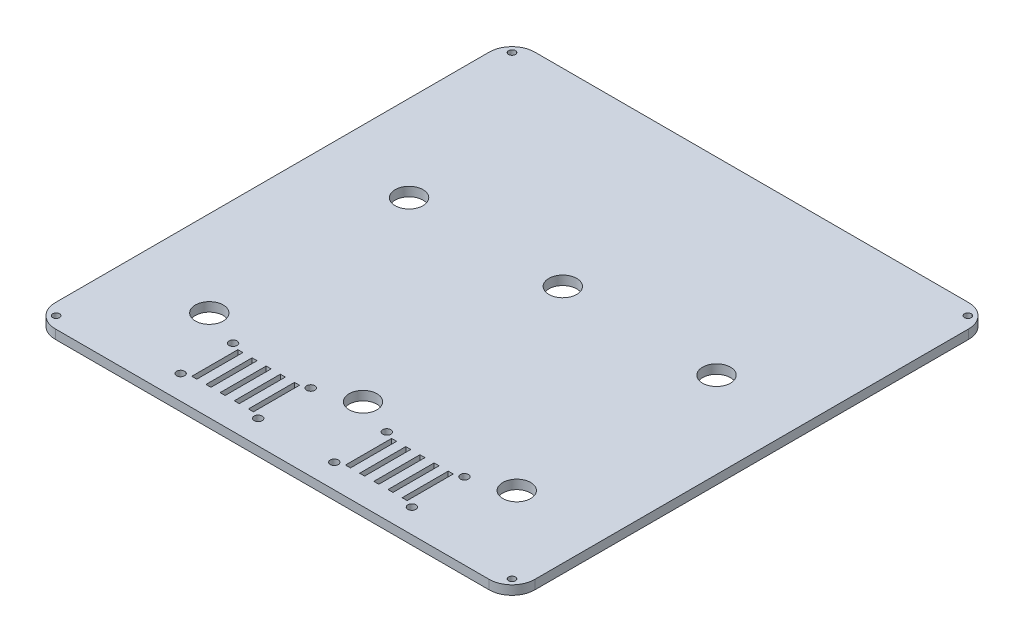
from build123d import *

# Parameters (mm, degrees)
SKETCH1_W         = 210
SKETCH1_H         = 210
SKETCH1_R         = 1.5
SKETCH1_R_2       = 6.1
SKETCH1_R_3       = 1.765
SKETCH1_W_2       = 2.2
SKETCH1_H_2       = 20.2
MAINEXTRUDE_DEPTH = 4
ROUNDEDCORNERS_R  = 10


with BuildPart() as part:
    # Sketch1 → MainExtrude (new body)
    with BuildSketch(Plane(origin=(0, 0, 0), x_dir=(1, 0, 0), z_dir=(0, 1, 0))):
        Rectangle(SKETCH1_W, SKETCH1_H)
        with Locations((-99.833273811, 99.833273811)):
            Circle(SKETCH1_R, mode=Mode.SUBTRACT)
        with Locations((-99.833273811, -99.833273811)):
            Circle(SKETCH1_R, mode=Mode.SUBTRACT)
        with Locations((99.833273811, -99.833273811)):
            Circle(SKETCH1_R, mode=Mode.SUBTRACT)
        with Locations((99.833273811, 99.833273811)):
            Circle(SKETCH1_R, mode=Mode.SUBTRACT)
        with Locations((67.333333333, -65.25)):
            Circle(SKETCH1_R_2, mode=Mode.SUBTRACT)
        with Locations((0, -65.25)):
            Circle(SKETCH1_R_2, mode=Mode.SUBTRACT)
        with Locations((-67.333333333, -65.25)):
            Circle(SKETCH1_R_2, mode=Mode.SUBTRACT)
        with Locations((-67.333333333, 22.25)):
            Circle(SKETCH1_R_2, mode=Mode.SUBTRACT)
        with Locations((0, 22.25)):
            Circle(SKETCH1_R_2, mode=Mode.SUBTRACT)
        with Locations((67.333333333, 22.25)):
            Circle(SKETCH1_R_2, mode=Mode.SUBTRACT)
        with Locations((-50.666666667, -71.5)):
            Circle(SKETCH1_R_3, mode=Mode.SUBTRACT)
        with Locations((-50.666666667, -94.5)):
            Circle(SKETCH1_R_3, mode=Mode.SUBTRACT)
        with Locations((-16.666666667, -94.5)):
            Circle(SKETCH1_R_3, mode=Mode.SUBTRACT)
        with Locations((-16.666666667, -71.5)):
            Circle(SKETCH1_R_3, mode=Mode.SUBTRACT)
        with Locations((16.666666667, -71.5)):
            Circle(SKETCH1_R_3, mode=Mode.SUBTRACT)
        with Locations((16.666666667, -94.5)):
            Circle(SKETCH1_R_3, mode=Mode.SUBTRACT)
        with Locations((50.666666667, -94.5)):
            Circle(SKETCH1_R_3, mode=Mode.SUBTRACT)
        with Locations((50.666666667, -71.5)):
            Circle(SKETCH1_R_3, mode=Mode.SUBTRACT)
        with Locations((-46.066666667, -83)):
            Rectangle(SKETCH1_W_2, SKETCH1_H_2, mode=Mode.SUBTRACT)
        with Locations((-39.866666667, -83)):
            Rectangle(SKETCH1_W_2, SKETCH1_H_2, mode=Mode.SUBTRACT)
        with Locations((-33.666666667, -83)):
            Rectangle(SKETCH1_W_2, SKETCH1_H_2, mode=Mode.SUBTRACT)
        with Locations((-27.466666667, -83)):
            Rectangle(SKETCH1_W_2, SKETCH1_H_2, mode=Mode.SUBTRACT)
        with Locations((-21.266666667, -83)):
            Rectangle(SKETCH1_W_2, SKETCH1_H_2, mode=Mode.SUBTRACT)
        with Locations((21.266666667, -83)):
            Rectangle(SKETCH1_W_2, SKETCH1_H_2, mode=Mode.SUBTRACT)
        with Locations((27.466666667, -83)):
            Rectangle(SKETCH1_W_2, SKETCH1_H_2, mode=Mode.SUBTRACT)
        with Locations((33.666666667, -83)):
            Rectangle(SKETCH1_W_2, SKETCH1_H_2, mode=Mode.SUBTRACT)
        with Locations((39.866666667, -83)):
            Rectangle(SKETCH1_W_2, SKETCH1_H_2, mode=Mode.SUBTRACT)
        with Locations((46.066666667, -83)):
            Rectangle(SKETCH1_W_2, SKETCH1_H_2, mode=Mode.SUBTRACT)
    extrude(amount=MAINEXTRUDE_DEPTH)

    # RoundedCorners
    roundedcorners_edges = [part.edges().sort_by_distance(p)[0] for p in [
        (-105, 2, 105),
        (-105, 2, -105),
        (105, 2, -105),
        (105, 2, 105),
    ]]
    fillet(roundedcorners_edges, radius=ROUNDEDCORNERS_R)


solid = part.part
